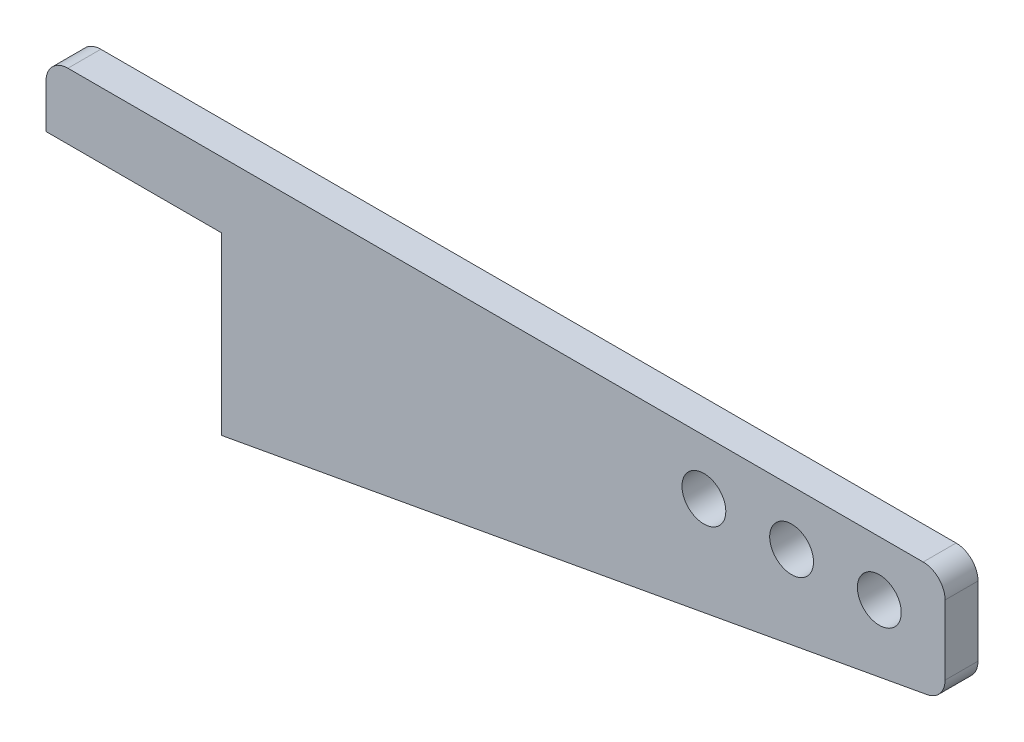
from build123d import *

# Parameters (mm, degrees)
ESQUISSE1_R        = 10
BOSS_EXTRU_1_DEPTH = 15
CONG_1_R           = 10


with BuildPart() as part:
    # Esquisse1 → Boss.-Extru.1 (new body)
    with BuildSketch(Plane.XY):
        Polygon((0, 0), (410, 0), (410, -50), (80, -110), (80, -30), (0, -30), align=None)
        with Locations((300, -25)):
            Circle(ESQUISSE1_R, mode=Mode.SUBTRACT)
        with Locations((340, -25)):
            Circle(ESQUISSE1_R, mode=Mode.SUBTRACT)
        with Locations((380, -25)):
            Circle(ESQUISSE1_R, mode=Mode.SUBTRACT)
    extrude(amount=BOSS_EXTRU_1_DEPTH)

    # Congé1
    cong_1_edges = [part.edges().sort_by_distance(p)[0] for p in [
        (0, 0, 7.5),
        (410, 0, 7.5),
        (410, -50, 7.5),
    ]]
    fillet(cong_1_edges, radius=CONG_1_R)


solid = part.part
